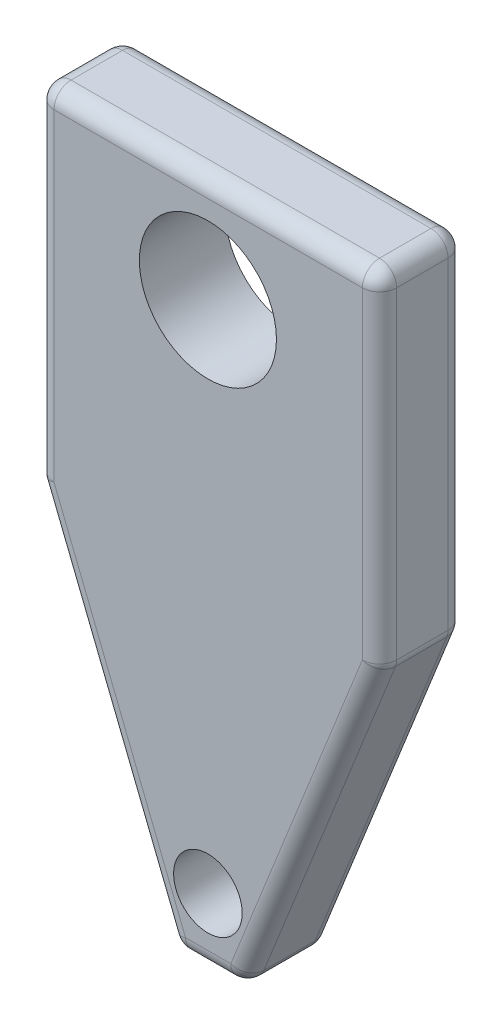
from build123d import *

# Parameters (mm, degrees)
SKETCH1_R           = 4
SKETCH1_R_2         = 2
BOSS_EXTRUDE1_DEPTH = 5
FILLET1_R           = 1


with BuildPart() as part:
    # Sketch1 → Boss-Extrude1 (new body)
    with BuildSketch(Plane.XY):
        Polygon((0, -20), (8, -40), (12, -40), (20, -20), (20, 0), (0, 0), align=None)
        with Locations((9.984598527, -6.114863432)):
            Circle(SKETCH1_R, mode=Mode.SUBTRACT)
        with Locations((9.984598527, -36.114863432)):
            Circle(SKETCH1_R_2, mode=Mode.SUBTRACT)
    extrude(amount=BOSS_EXTRUDE1_DEPTH)

    # Fillet1
    fillet1_edges = [part.edges().sort_by_distance(p)[0] for p in [
        (10, -40, 5),
        (0, 0, 2.5),
        (20, 0, 2.5),
        (20, -20, 2.5),
        (12, -40, 2.5),
        (8, -40, 2.5),
        (0, -20, 2.5),
        (16, -30, 5),
        (20, -10, 5),
        (10, 0, 5),
        (0, -10, 5),
        (10, 0, 0),
        (20, -10, 0),
        (16, -30, 0),
        (4, -30, 5),
        (10, -40, 0),
        (4, -30, 0),
        (0, -10, 0),
    ]]
    fillet(fillet1_edges, radius=FILLET1_R)


solid = part.part
